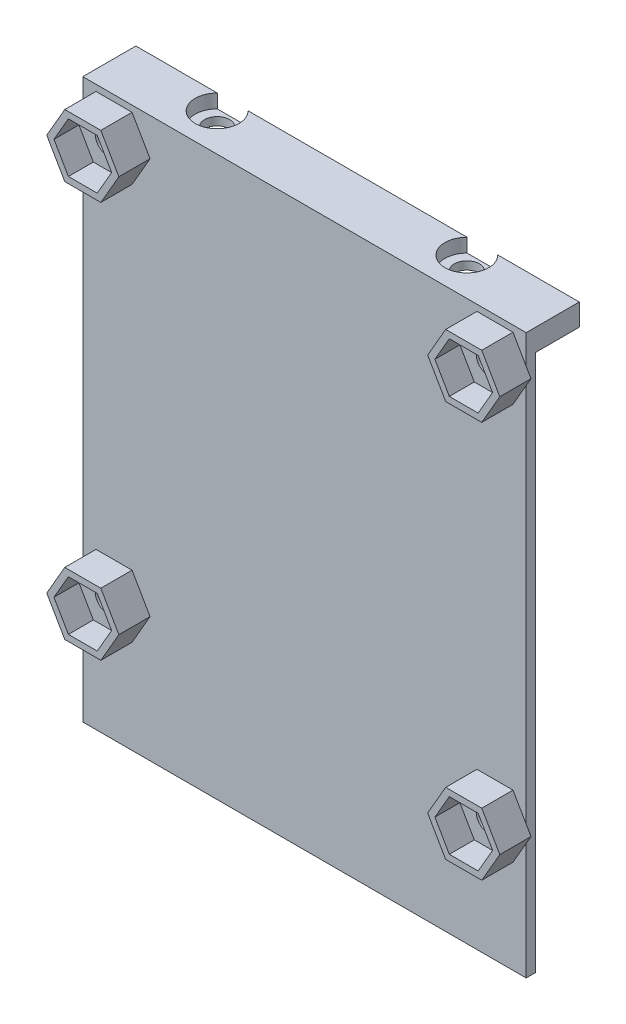
from build123d import *

# Parameters (mm, degrees)
SKETCH2_W           = 71
SKETCH2_H           = 73.5
BOSS_EXTRUDE1_DEPTH = 1.5
BOSS_EXTRUDE2_DEPTH = 5
SKETCH20_W          = 71
SKETCH20_H          = 1
BOSS_EXTRUDE6_DEPTH = 1.5
SKETCH12_W          = 71
SKETCH12_H          = 7
BOSS_EXTRUDE3_DEPTH = 3.5
SKETCH13_R          = 2
CUT_EXTRUDE3_DEPTH  = 75.5
SKETCH14_R          = 3.5
CUT_EXTRUDE4_DEPTH  = 2.2
SKETCH15_W          = 71
SKETCH15_H          = 1.5
BOSS_EXTRUDE4_DEPTH = 15
SKETCH16_R          = 4
SKETCH16_R_2        = 2.75
BOSS_EXTRUDE5_DEPTH = 4.5
CUT_EXTRUDE5_DEPTH  = 4
SKETCH19_R          = 2
CUT_EXTRUDE6_DEPTH  = 14.5


with BuildPart() as part:
    # Sketch2 → Boss-Extrude1 (new body)
    with BuildSketch(Plane.XY):
        with Locations((35.5, 36.75)):
            Rectangle(SKETCH2_W, SKETCH2_H)
    extrude(amount=BOSS_EXTRUDE1_DEPTH)

    # Sketch3 → Boss-Extrude2 (add)
    with BuildSketch(Plane.XY.offset(1.5)):
        Polygon((10.773502692, 68.5), (7.886751346, 73.5), (2.113248654, 73.5), (-0.773502692, 68.5), (2.113248654, 63.5), (7.886751346, 63.5), align=None)
        Polygon((63.113248654, 63.5), (60.226497308, 68.5), (63.113248654, 73.5), (68.886751346, 73.5), (71.773502692, 68.5), (68.886751346, 63.5), align=None)
        Polygon((60.226497308, 5), (63.113248654, 0), (68.886751346, 0), (71.773502692, 5), (68.886751346, 10), (63.113248654, 10), align=None)
        Polygon((7.886751346, 10), (10.773502692, 5), (7.886751346, 0), (2.113248654, 0), (-0.773502692, 5), (2.113248654, 10), align=None)
    extrude(amount=BOSS_EXTRUDE2_DEPTH)

    # Sketch20 → Boss-Extrude6 (add)
    with BuildSketch(Plane.XY.offset(1.5)):
        with Locations((35.5, 74)):
            Rectangle(SKETCH20_W, SKETCH20_H)
    extrude(amount=-BOSS_EXTRUDE6_DEPTH)

    # Sketch12 → Boss-Extrude3 (add)
    with BuildSketch(Plane.XZ.offset(-74.5)):
        with Locations((35.5, -3.5)):
            Rectangle(SKETCH12_W, SKETCH12_H)
    extrude(amount=BOSS_EXTRUDE3_DEPTH)

    # Sketch13 → Cut-Extrude3 (cut, through all)
    with BuildSketch(Plane.XZ):
        with Locations((55.5, -4.5)):
            Circle(SKETCH13_R)
        with Locations((15.5, -4.5)):
            Circle(SKETCH13_R)
    extrude(amount=-CUT_EXTRUDE3_DEPTH, mode=Mode.SUBTRACT)

    # Sketch14 → Cut-Extrude4 (cut)
    with BuildSketch(Plane(origin=(0, 74.5, 0), x_dir=(-1, 0, 0), z_dir=(0, -1, 0))):
        with Locations((-55.5, 4.5)):
            Circle(SKETCH14_R)
        with Locations((-15.5, 4.5)):
            Circle(SKETCH14_R)
    extrude(amount=CUT_EXTRUDE4_DEPTH, mode=Mode.SUBTRACT)

    # Sketch15 → Boss-Extrude4 (add)
    with BuildSketch(Plane.XZ):
        with Locations((35.5, 0.75)):
            Rectangle(SKETCH15_W, SKETCH15_H)
    extrude(amount=BOSS_EXTRUDE4_DEPTH)

    # Sketch16 → Boss-Extrude5 (add)
    with BuildSketch(Plane.XY.offset(1.5)):
        with Locations((35.5, -10.5)):
            Circle(SKETCH16_R)
        with Locations((35.5, -10.5)):
            Circle(SKETCH16_R_2, mode=Mode.SUBTRACT)
    extrude(amount=-BOSS_EXTRUDE5_DEPTH)

    # Sketch17 → Cut-Extrude5 (cut)
    with BuildSketch(Plane.XY.offset(6.5)):
        Polygon((7.309401077, 72.5), (2.690598923, 72.5), (0.381197846, 68.5), (2.690598923, 64.5), (7.309401077, 64.5), (9.618802154, 68.5), align=None)
        Polygon((68.309401077, 72.5), (63.690598923, 72.5), (61.381197846, 68.5), (63.690598923, 64.5), (68.309401077, 64.5), (70.618802154, 68.5), align=None)
        Polygon((68.309401077, 9), (63.690598923, 9), (61.381197846, 5), (63.690598923, 1), (68.309401077, 1), (70.618802154, 5), align=None)
        Polygon((7.309401077, 9), (2.690598923, 9), (0.381197846, 5), (2.690598923, 1), (7.309401077, 1), (9.618802154, 5), align=None)
    extrude(amount=-CUT_EXTRUDE5_DEPTH, mode=Mode.SUBTRACT)

    # Sketch19 → Cut-Extrude6 (cut, through all)
    with BuildSketch(Plane.XY.offset(6.5)):
        with Locations((5, 68.5)):
            Circle(SKETCH19_R)
        with Locations((66, 68.5)):
            Circle(SKETCH19_R)
        with Locations((5, 5)):
            Circle(SKETCH19_R)
        with Locations((66, 5)):
            Circle(SKETCH19_R)
    extrude(amount=-CUT_EXTRUDE6_DEPTH, mode=Mode.SUBTRACT)


solid = part.part
